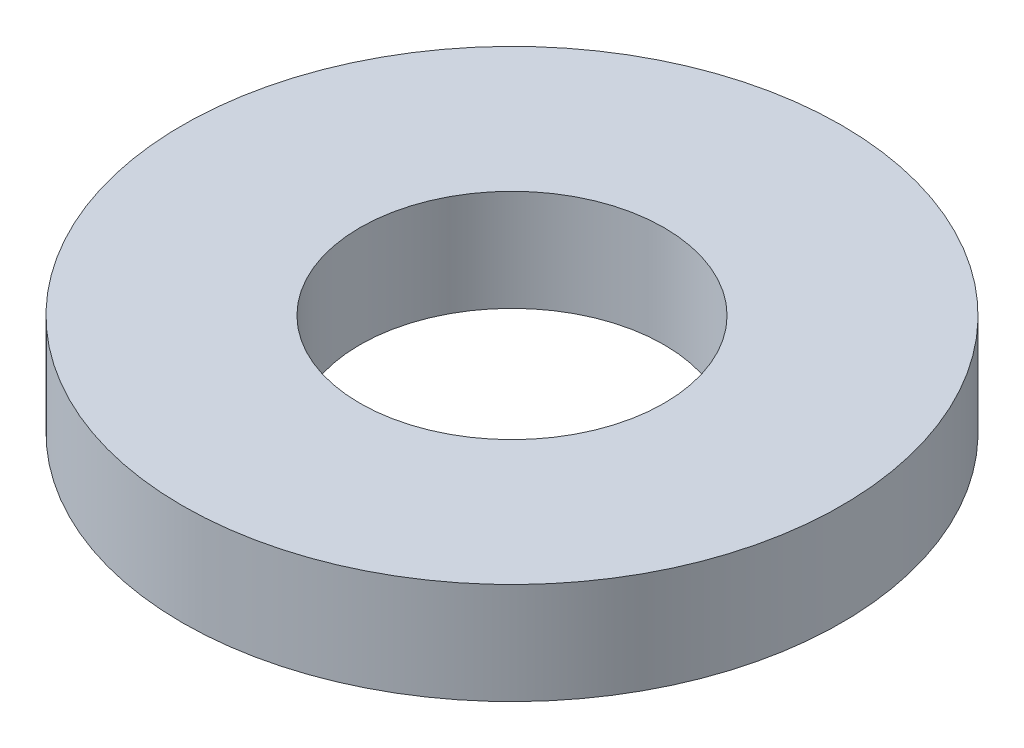
from build123d import *

# Parameters (mm, degrees)
SKETCH1_R           = 6.5
SKETCH1_R_2         = 3
BOSS_EXTRUDE1_DEPTH = 2


with BuildPart() as part:
    # Sketch1 → Boss-Extrude1 (new body)
    with BuildSketch(Plane(origin=(0, 0, 0), x_dir=(1, 0, 0), z_dir=(0, 1, 0))):
        Circle(SKETCH1_R)
        Circle(SKETCH1_R_2, mode=Mode.SUBTRACT)
    extrude(amount=BOSS_EXTRUDE1_DEPTH)


solid = part.part
